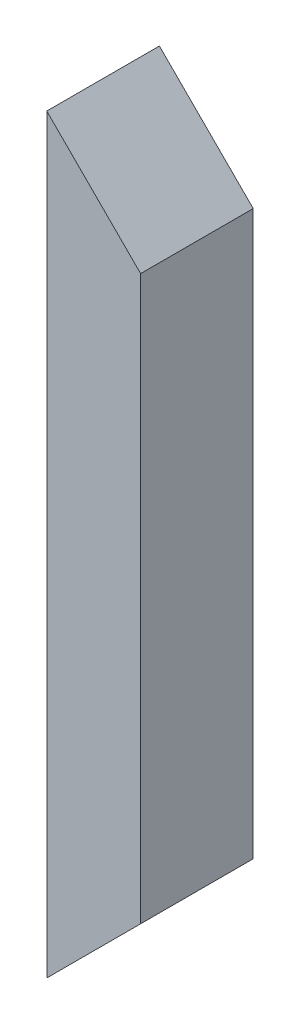
from build123d import *

# Parameters (mm, degrees)
SKETCH1_W           = 25
SKETCH1_H           = 30
BOSS_EXTRUDE1_DEPTH = 200
CUT_EXTRUDE1_DEPTH  = 200


with BuildPart() as part:
    # Sketch1 → Boss-Extrude1 (new body)
    with BuildSketch(Plane(origin=(0, 0, 0), x_dir=(1, 0, 0), z_dir=(0, 1, 0))):
        with Locations((12.5, 15)):
            Rectangle(SKETCH1_W, SKETCH1_H)
    extrude(amount=BOSS_EXTRUDE1_DEPTH)

    # Sketch2 → Cut-Extrude1 (cut)
    with BuildSketch(Plane.XY):
        Polygon((0, 0), (25, 0), (25, 25), align=None)
        Polygon((25, 175), (0, 200), (25, 200), align=None)
    extrude(amount=-CUT_EXTRUDE1_DEPTH, mode=Mode.SUBTRACT)


solid = part.part
